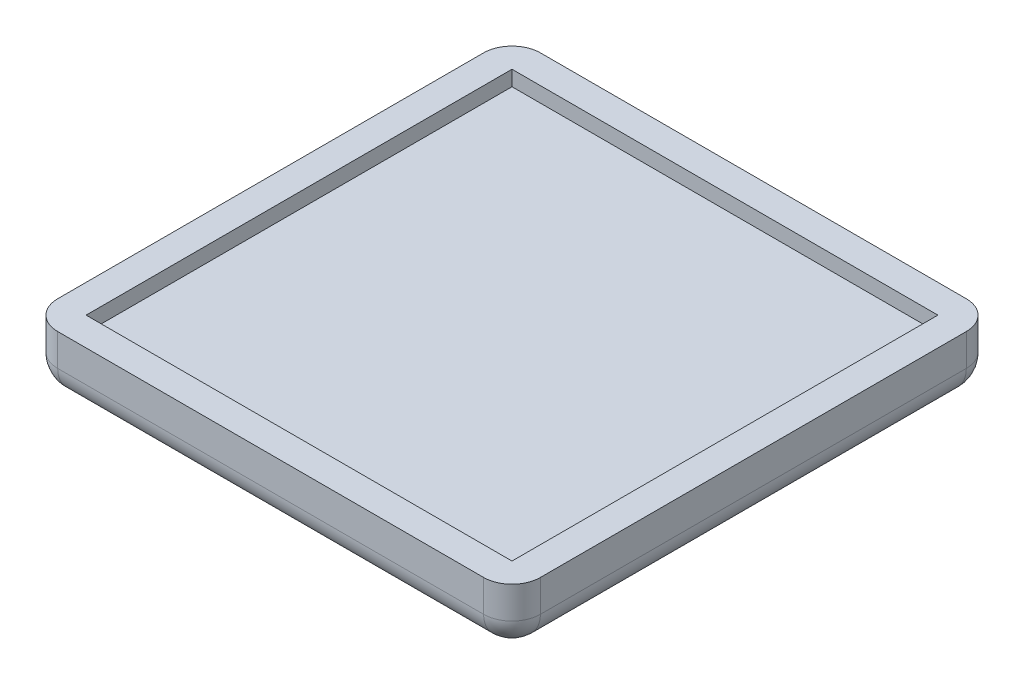
from build123d import *

# Parameters (mm, degrees)
SKETCH1_W           = 5.08
SKETCH1_H           = 5.08
BOSS_EXTRUDE1_DEPTH = 5.715
SKETCH2_W           = 86.36
SKETCH2_H           = 86.36
BOSS_EXTRUDE2_DEPTH = 5.08
FILLET1_R           = 5.08
SKETCH3_W           = 76.2
SKETCH3_H           = 76.2
BOSS_EXTRUDE3_DEPTH = 3


with BuildPart() as part:
    # Sketch1 → Boss-Extrude1 (new body)
    with BuildSketch(Plane(origin=(0, 0, 0), x_dir=(1, 0, 0), z_dir=(0, 1, 0))):
        Polygon((-5.08, 0), (0, 0), (0, 76.2), (76.2, 76.2), (76.2, 81.28), (-5.08, 81.28), align=None)
        Polygon((76.2, 0), (0, 0), (0, -5.08), (81.28, -5.08), (81.28, 76.2), (76.2, 76.2), align=None)
        with Locations((-2.54, -2.54)):
            Rectangle(SKETCH1_W, SKETCH1_H)
        with Locations((78.74, 78.74)):
            Rectangle(SKETCH1_W, SKETCH1_H)
    extrude(amount=-BOSS_EXTRUDE1_DEPTH)

    # Sketch2 → Boss-Extrude2 (add)
    with BuildSketch(Plane(origin=(0, -5.715, 0), x_dir=(-1, 0, 0), z_dir=(0, -1, 0))):
        with Locations((-38.1, 38.1)):
            Rectangle(SKETCH2_W, SKETCH2_H)
    extrude(amount=BOSS_EXTRUDE2_DEPTH)

    # Fillet1
    fillet1_edges = [part.edges().sort_by_distance(p)[0] for p in [
        (-5.08, -5.3975, 5.08),
        (-5.08, -5.3975, -81.28),
        (81.28, -5.3975, -81.28),
        (81.28, -5.3975, 5.08),
        (-5.08, -10.795, -38.1),
        (38.1, -10.795, -81.28),
        (81.28, -10.795, -38.1),
        (38.1, -10.795, 5.08),
    ]]
    fillet(fillet1_edges, radius=FILLET1_R)

    # Sketch3 → Boss-Extrude3 (add)
    with BuildSketch(Plane(origin=(0, -5.715, 0), x_dir=(1, 0, 0), z_dir=(0, 1, 0))):
        with Locations((38.1, 38.1)):
            Rectangle(SKETCH3_W, SKETCH3_H)
    extrude(amount=BOSS_EXTRUDE3_DEPTH)


solid = part.part
